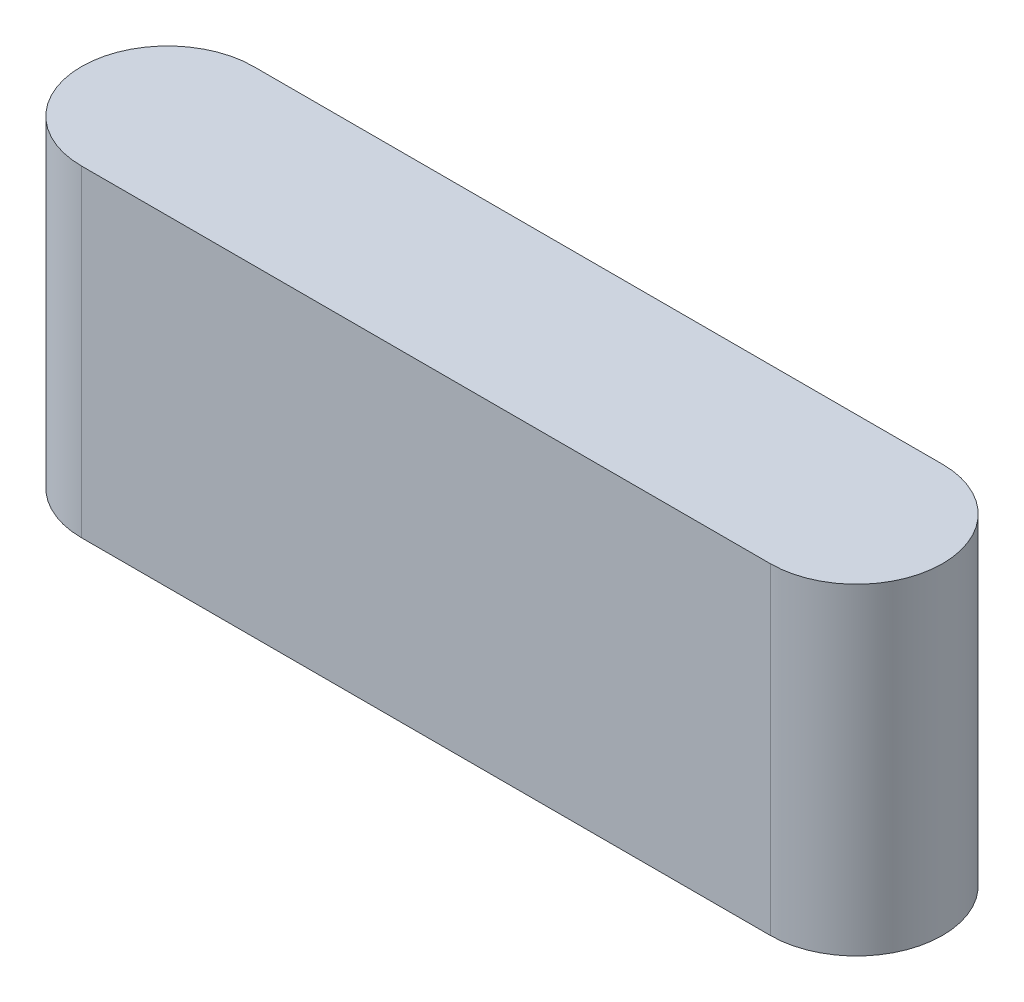
from build123d import *

# Parameters (mm, degrees)
BOSS_EXTRUDE1_DEPTH = 43


with BuildPart() as part:
    # Sketch1 → Boss-Extrude1 (new body)
    with BuildSketch(Plane(origin=(0, 0, 0), x_dir=(1, 0, 0), z_dir=(0, 1, 0))):
        with BuildLine():
            Line((0, 11.5), (92, 11.5))
            ThreePointArc((92, 11.5), (103.5, 0), (92, -11.5))
            Line((92, -11.5), (0, -11.5))
            ThreePointArc((0, -11.5), (-11.5, 0), (0, 11.5))
        make_face()
    extrude(amount=BOSS_EXTRUDE1_DEPTH)


solid = part.part
